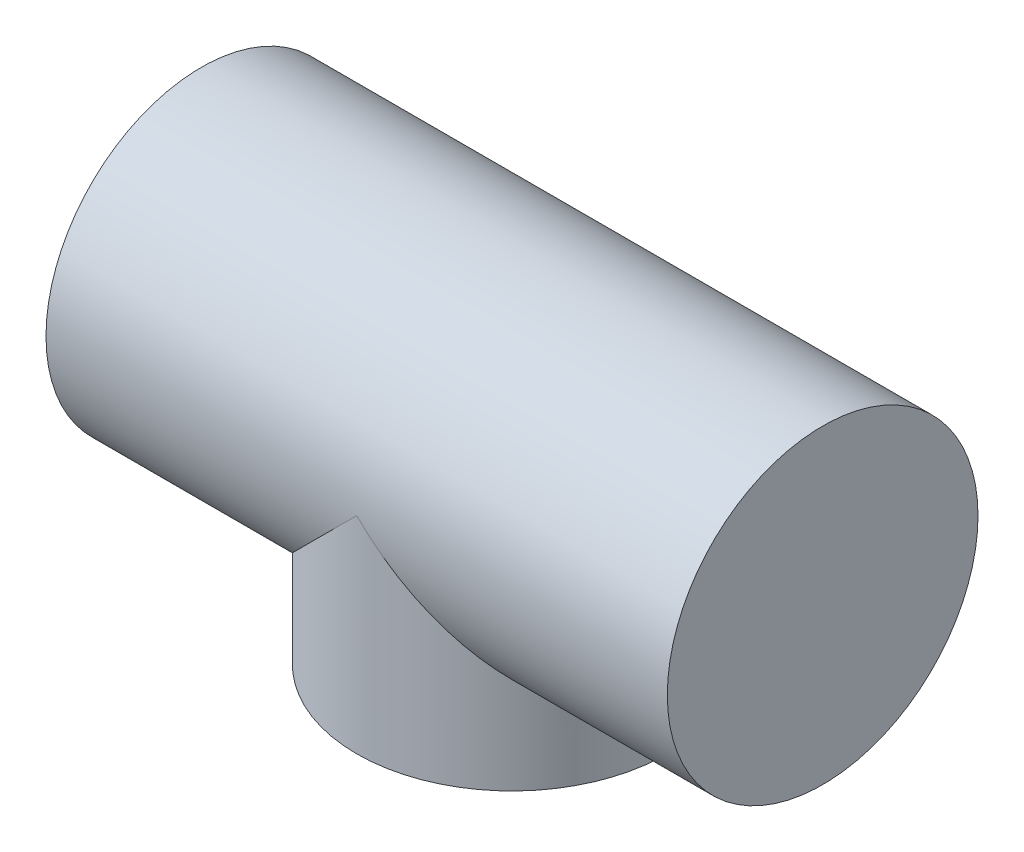
from build123d import *

# Parameters (mm, degrees)
SKETCH2_R           = 25
SKETCH4_R           = 25
BOSS_EXTRUDE1_DEPTH = 33.2


with BuildPart() as part:
    # Sweep1: sweep along a path in Sketch1
    with BuildLine(Plane.XY) as sweep1_path:
        Line((0, 0), (100, 0))
    # Sketch2 → Sweep1 (sweep)
    with BuildSketch(Plane(origin=(0, 0, 0), x_dir=(0, 0, -1), z_dir=(1, 0, 0))):
        Circle(SKETCH2_R)
    sweep(path=sweep1_path.line)

    # Sketch4 → Boss-Extrude1 (add)
    with BuildSketch(Plane(origin=(0, 0, 0), x_dir=(1, 0, 0), z_dir=(0, 1, 0))):
        with Locations((50, 0)):
            Circle(SKETCH4_R)
    extrude(amount=-BOSS_EXTRUDE1_DEPTH)


solid = part.part
